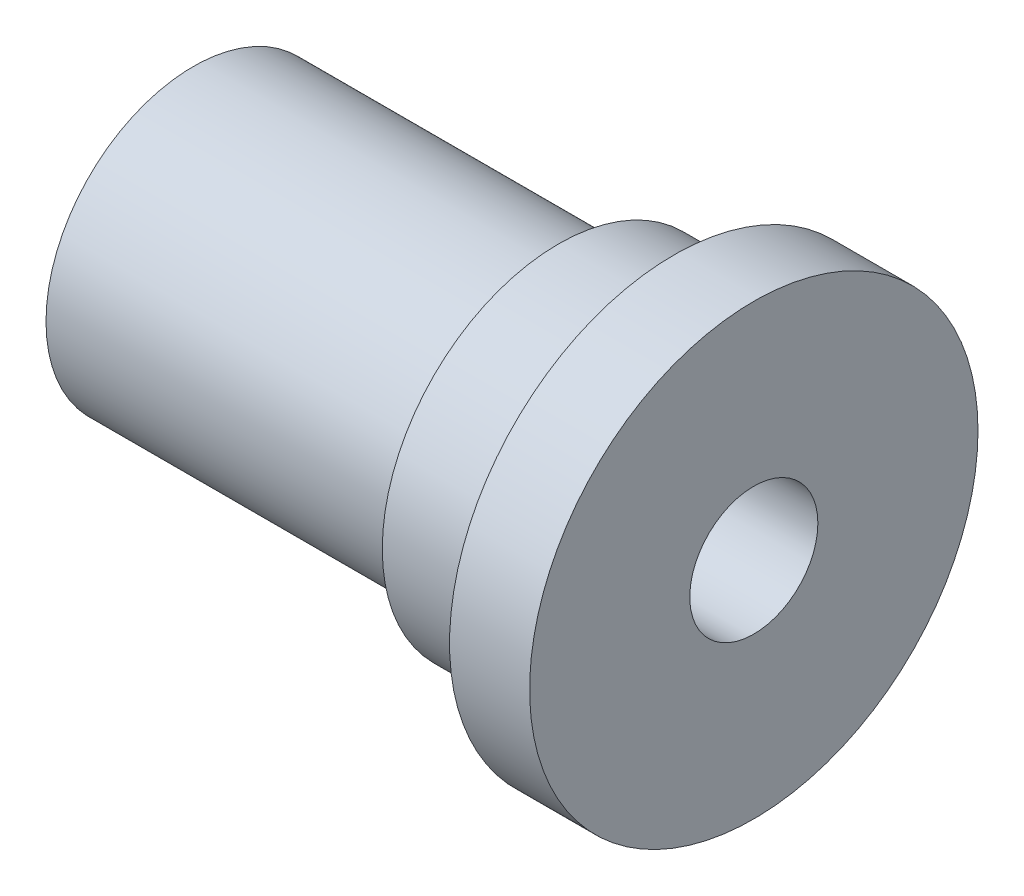
from build123d import *

# Parameters (mm, degrees)
SKETCH3_R          = 2.5
CUT_EXTRUDE1_DEPTH = 10


with BuildPart() as part:
    # Sketch1 → Revolve1 (revolve)
    with BuildSketch(Plane(origin=(0, 0, 0), x_dir=(1, 0, 0), z_dir=(0, 1, 0))):
        Polygon((0, 11), (-7.2, 11), (-7.2, 9.2), (-30, 9.2), (-30, 0), (-18, 0), (-18, 4), (0, 4), (5, 4), (5, 14), (0, 14), align=None)
    revolve(axis=Axis((-18, 0, 0), (-1, 0, 0)))

    # Sketch3 → Cut-Extrude1 (cut)
    with BuildSketch(Plane(origin=(0, 0, 0), x_dir=(1, 0, 0), z_dir=(0, 1, 0))):
        with Locations((-11, 0)):
            Circle(SKETCH3_R)
    extrude(amount=-CUT_EXTRUDE1_DEPTH, mode=Mode.SUBTRACT)


solid = part.part
